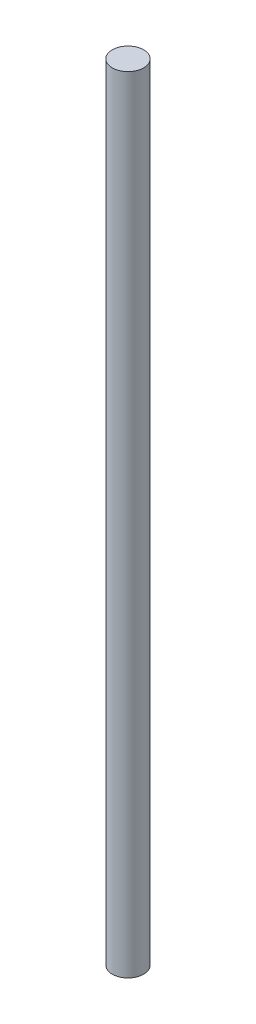
from build123d import *

# Parameters (mm, degrees)
SKETCH1_R           = 4
BOSS_EXTRUDE1_DEPTH = 200


with BuildPart() as part:
    # Sketch1 → Boss-Extrude1 (new body)
    with BuildSketch(Plane(origin=(0, 0, 0), x_dir=(1, 0, 0), z_dir=(0, 1, 0))):
        Circle(SKETCH1_R)
    extrude(amount=BOSS_EXTRUDE1_DEPTH)


solid = part.part
